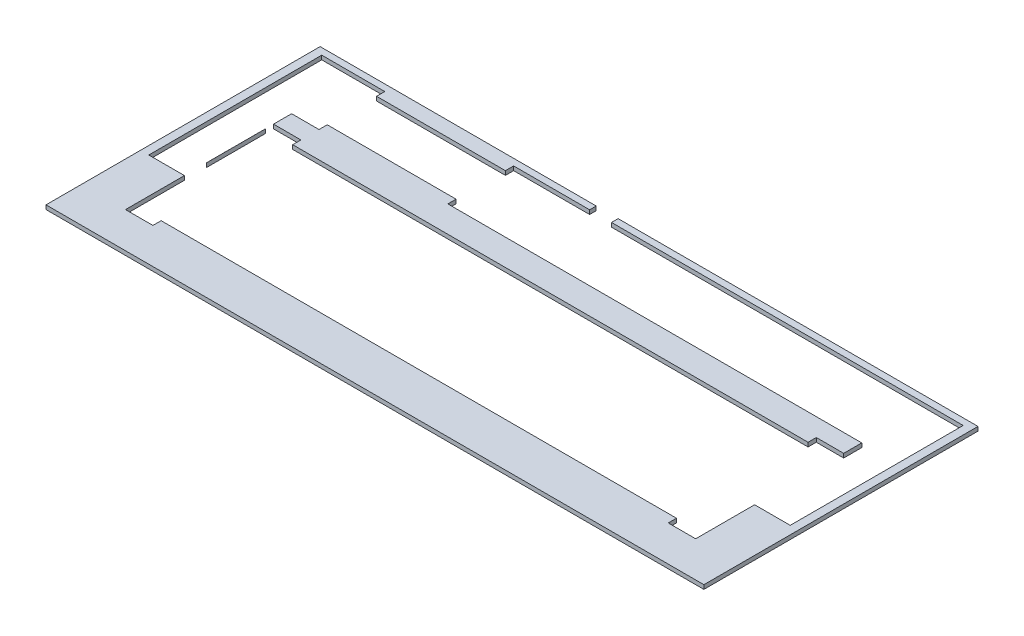
from build123d import *

# Parameters (mm, degrees)
CROQUIS1_W              = 486.2
CROQUIS1_H              = 206.2
CROQUIS1_W_2            = 480
CROQUIS1_H_2            = 200
SALIENTE_EXTRUIR1_DEPTH = 12
CROQUIS3_W              = 486.2
CROQUIS3_H              = 206.2
CROQUIS3_W_2            = 480
CROQUIS3_H_2            = 200
CORTAR_EXTRUIR1_DEPTH   = 5
CORTAR_EXTRUIR3_DEPTH   = 8
CROQUIS4_W              = 20
CROQUIS4_H              = 6
CORTAR_EXTRUIR4_DEPTH   = 3
CORTAR_EXTRUIR5_DEPTH   = 2
CROQUIS7_W              = 721.947089947
CROQUIS7_H              = 359.419856831
CORTAR_EXTRUIR6_DEPTH   = 10
CROQUIS8_W              = 416
CROQUIS8_H              = 96
CORTAR_EXTRUIR7_DEPTH   = 10
CROQUIS9_W              = 531.904745737
CROQUIS9_H              = 246.353411826
CORTAR_EXTRUIR8_DEPTH   = 10


with BuildPart() as part:
    # Croquis1 → Saliente-Extruir1 (new body)
    with BuildSketch(Plane(origin=(0, 0, 0), x_dir=(1, 0, 0), z_dir=(0, 1, 0))):
        with Locations((240, 100)):
            Rectangle(CROQUIS1_W, CROQUIS1_H)
        with Locations((240, 100)):
            Rectangle(CROQUIS1_W_2, CROQUIS1_H_2, mode=Mode.SUBTRACT)
        with Locations((240, 100)):
            Rectangle(CROQUIS1_W_2, CROQUIS1_H_2)
    extrude(amount=SALIENTE_EXTRUIR1_DEPTH)

    # Croquis3 → Cortar-Extruir1 (cut)
    with BuildSketch(Plane(origin=(0, 12, 0), x_dir=(1, 0, 0), z_dir=(0, 1, 0))):
        with Locations((240, 100)):
            Rectangle(CROQUIS3_W, CROQUIS3_H)
        with Locations((240, 100)):
            Rectangle(CROQUIS3_W_2, CROQUIS3_H_2, mode=Mode.SUBTRACT)
    extrude(amount=-CORTAR_EXTRUIR1_DEPTH, mode=Mode.SUBTRACT)

    # Croquis2 → Cortar-Extruir3 (cut)
    with BuildSketch(Plane(origin=(0, 12, 0), x_dir=(1, 0, 0), z_dir=(0, 1, 0))):
        with BuildLine():
            ThreePointArc((16, 189.1902066), (13.171572875, 188.018633725), (12, 185.1902066))
            Line((12, 185.1902066), (12, 78))
            ThreePointArc((12, 78), (12.878679656, 75.878679656), (15, 75))
            Line((15, 75), (32, 75))
            Line((32, 75), (32, 32))
            Line((32, 32), (448, 32))
            Line((448, 32), (448, 75))
            Line((448, 75), (464, 75))
            ThreePointArc((464, 75), (466.828427125, 76.171572875), (468, 79))
            Line((468, 79), (468, 185.1902066))
            ThreePointArc((468, 185.1902066), (466.828427125, 188.018633725), (464, 189.1902066))
            Line((464, 189.1902066), (217.424703227, 189.1902066))
            Line((217.424703227, 189.1902066), (217.424703227, 203.1))
            Line((217.424703227, 203.1), (201.44869327, 203.1))
            Line((201.44869327, 203.1), (201.44869327, 189.1902066))
            Line((201.44869327, 189.1902066), (16, 189.1902066))
        make_face()
        with BuildLine():
            Line((32, 85), (31.963588191, 85))
            ThreePointArc((31.963588191, 85), (24.892520379, 87.928932188), (21.963588191, 95))
            Line((21.963588191, 95), (21.963588191, 175.1902066))
            ThreePointArc((21.963588191, 175.1902066), (23.135161066, 178.018633725), (25.963588191, 179.1902066))
            Line((25.963588191, 179.1902066), (28, 179.1902066))
            ThreePointArc((28, 179.1902066), (30.828427125, 178.018633725), (32, 175.1902066))
            Line((32, 175.1902066), (32, 153.1902066))
            Line((32, 153.1902066), (166, 153.1902066))
            Line((166, 153.1902066), (166, 175.1902066))
            ThreePointArc((166, 175.1902066), (167.171572875, 178.018633725), (170, 179.1902066))
            Line((170, 179.1902066), (448.036411809, 179.1902066))
            ThreePointArc((448.036411809, 179.1902066), (455.107479621, 176.261274412), (458.036411809, 169.1902066))
            Line((458.036411809, 169.1902066), (458.036411809, 135.000000034))
            Line((458.036411809, 135.000000034), (458.803569043, 95.19268186))
            ThreePointArc((458.803569043, 95.19268186), (455.944291637, 87.997386866), (448.80542553, 85))
            Line((448.80542553, 85), (448, 85))
            Line((448, 85), (448, 128))
            Line((448, 128), (32, 128))
            Line((32, 128), (32, 85))
        make_face(mode=Mode.SUBTRACT)
    extrude(amount=-CORTAR_EXTRUIR3_DEPTH, mode=Mode.SUBTRACT)

    # Croquis4 → Cortar-Extruir4 (cut)
    with BuildSketch(Plane(origin=(0, 12, 0), x_dir=(1, 0, 0), z_dir=(0, 1, 0))):
        with BuildLine():
            Line((31.963588191, 85), (32, 128))
            Line((32, 128), (32, 134))
            Line((32, 134), (32, 147.1902066))
            Line((32, 147.1902066), (32, 153.1902066))
            Line((32, 153.1902066), (32, 175.1902066))
            ThreePointArc((32, 175.1902066), (30.828427125, 178.018633725), (28, 179.1902066))
            Line((28, 179.1902066), (25.963588191, 179.1902066))
            ThreePointArc((25.963588191, 179.1902066), (23.135161066, 178.018633725), (21.963588191, 175.1902066))
            Line((21.963588191, 175.1902066), (21.963588191, 95))
            ThreePointArc((21.963588191, 95), (24.892520379, 87.928932188), (31.963588191, 85))
        make_face()
        with Locations((42, 131)):
            Rectangle(CROQUIS4_W, CROQUIS4_H)
        with Locations((42, 150.1902066)):
            Rectangle(CROQUIS4_W, CROQUIS4_H)
        with BuildLine():
            ThreePointArc((12, 78), (12.878679656, 75.878679656), (15, 75))
            Line((15, 75), (32, 75))
            Line((32, 75), (32, 69))
            Line((32, 69), (6, 69))
            Line((6, 69), (6, 80))
            Line((6, 80), (6, 195.1902066))
            Line((6, 195.1902066), (16, 195.1902066))
            Line((16, 195.1902066), (32, 195.1902066))
            Line((32, 195.1902066), (32, 189.1902066))
            Line((32, 189.1902066), (16, 189.1902066))
            ThreePointArc((16, 189.1902066), (13.171572875, 188.018633725), (12, 185.1902066))
            Line((12, 185.1902066), (12, 80))
            Line((12, 80), (12, 78))
        make_face()
        with Locations((42, 192.1902066)):
            Rectangle(CROQUIS4_W, CROQUIS4_H)
        with Locations((42, 29)):
            Rectangle(CROQUIS4_W, CROQUIS4_H)
        with Locations((156, 192.1902066)):
            Rectangle(CROQUIS4_W, CROQUIS4_H)
        with Locations((156, 150.1902066)):
            Rectangle(CROQUIS4_W, CROQUIS4_H)
        with BuildLine():
            Line((166, 147.1902066), (448, 147.1902066))
            Line((448, 147.1902066), (458.036411809, 147.1902066))
            Line((458.036411809, 147.1902066), (458.036411809, 169.1902066))
            ThreePointArc((458.036411809, 169.1902066), (455.107479621, 176.261274412), (448.036411809, 179.1902066))
            Line((448.036411809, 179.1902066), (170, 179.1902066))
            ThreePointArc((170, 179.1902066), (167.171572875, 178.018633725), (166, 175.1902066))
            Line((166, 175.1902066), (166, 153.1902066))
            Line((166, 153.1902066), (166, 147.1902066))
        make_face()
        with BuildLine():
            Line((458.036411809, 169.1902066), (458.036411809, 147.1902066))
            Line((458.036411809, 147.1902066), (474, 147.1902066))
            Line((474, 147.1902066), (474, 195.1902066))
            Line((474, 195.1902066), (166, 195.1902066))
            Line((166, 195.1902066), (166, 189.1902066))
            Line((166, 189.1902066), (166, 175.1902066))
            ThreePointArc((166, 175.1902066), (167.171572875, 178.018633725), (170, 179.1902066))
            Line((170, 179.1902066), (448.036411809, 179.1902066))
            ThreePointArc((448.036411809, 179.1902066), (455.107479621, 176.261274412), (458.036411809, 169.1902066))
        make_face()
        with BuildLine():
            Line((448.80542553, 85), (448, 85))
            Line((448, 85), (448, 69))
            Line((448, 69), (474, 69))
            Line((474, 69), (474, 147.1902066))
            Line((474, 147.1902066), (458.036411809, 147.1902066))
            Line((458.036411809, 147.1902066), (458.036411809, 135.000000034))
            Line((458.036411809, 135.000000034), (458.803569043, 95.19268186))
            ThreePointArc((458.803569043, 95.19268186), (455.944291637, 87.997386866), (448.80542553, 85))
        make_face()
        with Locations((438, 131)):
            Rectangle(CROQUIS4_W, CROQUIS4_H)
        with Locations((438, 29)):
            Rectangle(CROQUIS4_W, CROQUIS4_H)
        with BuildLine():
            Line((448, 134), (448, 128))
            Line((448, 128), (448, 85))
            Line((448, 85), (448.80542553, 85))
            ThreePointArc((448.80542553, 85), (455.944291637, 87.997386866), (458.803569043, 95.19268186))
            Line((458.803569043, 95.19268186), (458.036411809, 135.000000034))
            Line((458.036411809, 135.000000034), (458.036411809, 147.1902066))
            Line((458.036411809, 147.1902066), (448, 147.1902066))
            Line((448, 147.1902066), (448, 134))
        make_face()
    extrude(amount=-CORTAR_EXTRUIR4_DEPTH, mode=Mode.SUBTRACT)

    # Croquis5 → Cortar-Extruir5 (cut)
    with BuildSketch(Plane(origin=(0, 4, 0), x_dir=(1, 0, 0), z_dir=(0, 1, 0))):
        with BuildLine():
            Line((32.046028397, 84.926485337), (32, 75))
            Line((32, 75), (15, 75))
            ThreePointArc((15, 75), (12.878679656, 75.878679656), (12, 78))
            Line((12, 78), (12, 185.1902066))
            ThreePointArc((12, 185.1902066), (13.171572875, 188.018633725), (16, 189.1902066))
            Line((16, 189.1902066), (201.44869327, 189.1902066))
            Line((201.44869327, 189.1902066), (201.44869327, 203.1))
            Line((201.44869327, 203.1), (217.424703227, 203.1))
            Line((217.424703227, 203.1), (217.424703227, 189.1902066))
            Line((217.424703227, 189.1902066), (464, 189.1902066))
            ThreePointArc((464, 189.1902066), (466.828427125, 188.018633725), (468, 185.1902066))
            Line((468, 185.1902066), (468, 79))
            ThreePointArc((468, 79), (466.828427125, 76.171572875), (464, 75))
            Line((464, 75), (448, 75))
            Line((448, 75), (448, 85))
            Line((448, 85), (448.80542553, 85))
            ThreePointArc((448.80542553, 85), (455.917657262, 88.023512896), (458.803569043, 95.19268186))
            Line((458.803569043, 95.19268186), (458.036411809, 169.1902066))
            ThreePointArc((458.036411809, 169.1902066), (455.107479621, 176.261274412), (448.036411809, 179.1902066))
            Line((448.036411809, 179.1902066), (170, 179.1902066))
            ThreePointArc((170, 179.1902066), (167.171572875, 178.018633725), (166, 175.1902066))
            Line((166, 175.1902066), (166, 153.1902066))
            Line((166, 153.1902066), (32, 153.1902066))
            Line((32, 153.1902066), (32, 175.1902066))
            ThreePointArc((32, 175.1902066), (30.828427125, 178.018633725), (28, 179.1902066))
            Line((28, 179.1902066), (25.963588191, 179.1902066))
            ThreePointArc((25.963588191, 179.1902066), (23.135161066, 178.018633725), (21.963588191, 175.1902066))
            Line((21.963588191, 175.1902066), (21.963588191, 95))
            ThreePointArc((21.963588191, 95), (24.91720844, 87.873793117), (32.046028397, 84.926485337))
        make_face()
    extrude(amount=-CORTAR_EXTRUIR5_DEPTH, mode=Mode.SUBTRACT)

    # Croquis7 → Cortar-Extruir6 (cut)
    with BuildSketch(Plane(origin=(0, 2, 0), x_dir=(1, 0, 0), z_dir=(0, 1, 0))):
        with Locations((149.368191722, 161.470369199)):
            Rectangle(CROQUIS7_W, CROQUIS7_H)
    extrude(amount=-CORTAR_EXTRUIR6_DEPTH, mode=Mode.SUBTRACT)

    # Croquis8 → Cortar-Extruir7 (cut)
    with BuildSketch(Plane(origin=(0, 4, 0), x_dir=(1, 0, 0), z_dir=(0, 1, 0))):
        with Locations((240, 80)):
            Rectangle(CROQUIS8_W, CROQUIS8_H)
    extrude(amount=-CORTAR_EXTRUIR7_DEPTH, mode=Mode.SUBTRACT)


with BuildPart() as cortar_extruir7_piece_1:
    # of the separate pieces the step leaves, piece 1, a body of its own (cortar_extruir7_pieces)
    add(part.part.solids().sort_by_distance((483.1, 2, 3.1))[0])


with BuildPart() as cortar_extruir7_piece_2:
    # of the separate pieces the step leaves, piece 2, a body of its own (cortar_extruir7_pieces)
    add(part.part.solids().sort_by_distance((32, 2, -128))[0])


with BuildPart() as cortar_extruir8_tool:
    # Croquis9 → Cortar-Extruir8 (new body)
    with BuildSketch(Plane(origin=(0, 9, 0), x_dir=(1, 0, 0), z_dir=(0, 1, 0))):
        with Locations((247.004349215, 106.418772052)):
            Rectangle(CROQUIS9_W, CROQUIS9_H)
    extrude(amount=-CORTAR_EXTRUIR8_DEPTH)


with BuildPart() as cortar_extruir7_piece_1_1:
    add(cortar_extruir7_piece_1.part)

    # Cortar-Extruir8: cut by cortar_extruir8_tool
    add(cortar_extruir8_tool.part, mode=Mode.SUBTRACT)


with BuildPart() as cortar_extruir7_piece_2_1:
    add(cortar_extruir7_piece_2.part)

    # Cortar-Extruir8: cut by cortar_extruir8_tool
    add(cortar_extruir8_tool.part, mode=Mode.SUBTRACT)


solid = Compound([cortar_extruir7_piece_1_1.part, cortar_extruir7_piece_2_1.part])
